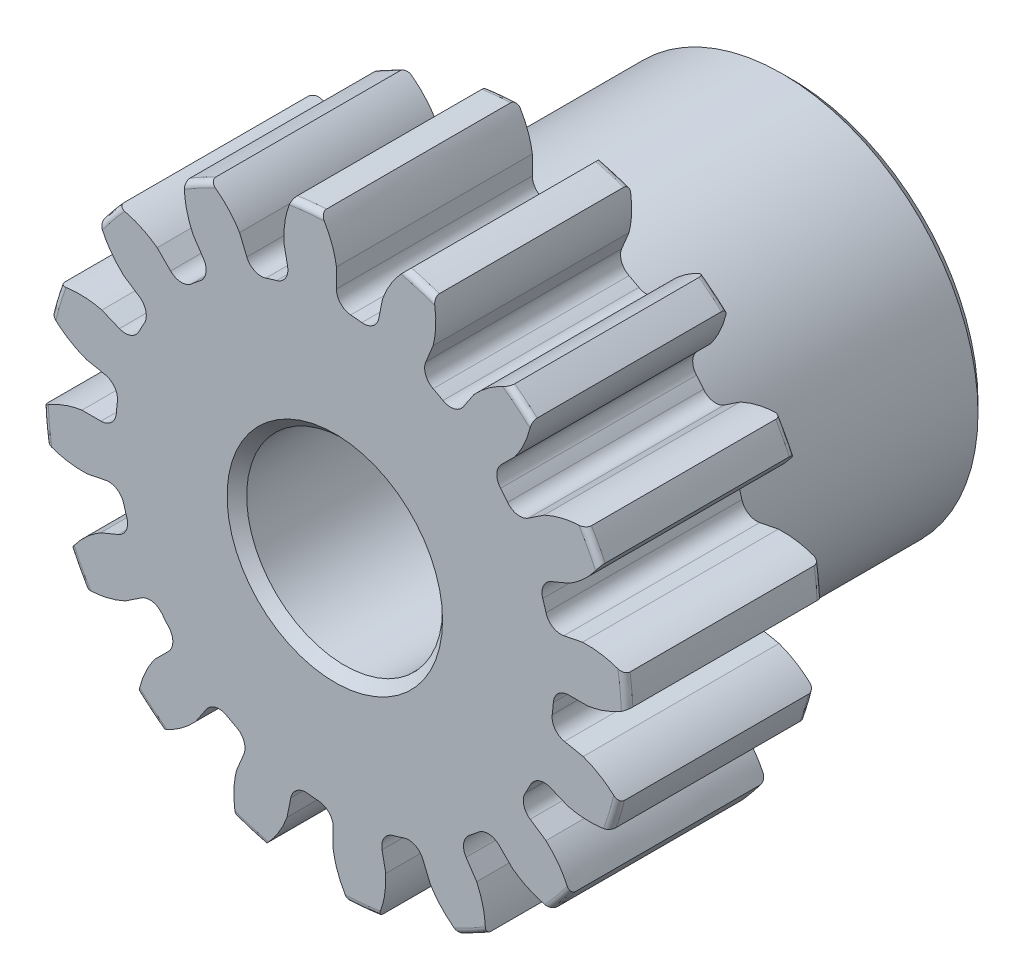
from build123d import *

# Parameters (mm, degrees)
SKETCH1_R                = 7.112
BOSS_EXTRUDE1_DEPTH      = 4.7625
SKETCH2_W                = 6.35
SKETCH2_H                = 4.7625
REVOLVE1_ANGLE           = 360
FILLET2_R                = 0.14224
CUT_EXTRUDE1_DEPTH       = 12.1125
FILLET1_R                = 0.37404675
CIRPATTERN1_COUNT        = 16
FILLET1_OF_CIRPATTERN1_R = 0.37404675
SKETCH5_R                = 2.38125
CUT_EXTRUDE2_DEPTH       = 12.1125
CHAMFER1_SIZE            = 0.238125


with BuildPart() as part:
    # Sketch1 → Boss-Extrude1 (new body)
    with BuildSketch(Plane.XY):
        Circle(SKETCH1_R)
    extrude(amount=-BOSS_EXTRUDE1_DEPTH)

    # Sketch2 → Revolve1 (revolve, symmetric)
    with BuildSketch(Plane(origin=(0, 0, 0), x_dir=(0, 0, -1), z_dir=(1, 0, 0))) as revolve1_sk:
        with Locations((7.9375, 2.38125)):
            Rectangle(SKETCH2_W, SKETCH2_H)
    revolve(axis=Axis((0, 0, -4.7625), (0, 0, -1)), revolution_arc=REVOLVE1_ANGLE / 2)
    revolve(revolve1_sk.sketch, axis=Axis((0, 0, -4.7625), (0, 0, 1)), revolution_arc=REVOLVE1_ANGLE / 2)

    # Fillet2
    fillet2_edges = [part.edges().sort_by_distance(p)[0] for p in [
        (-7.112, 0, 0),
        (-7.112, 0, -4.7625),
        (0, -4.7625, -4.7625),
    ]]
    fillet(fillet2_edges, radius=FILLET2_R)

    # Sketch4 → Cut-Extrude1 (cut, through all)
    with BuildSketch(Plane.XY):
        with BuildLine():
            Line((0.039756598, 6.147608965), (0.039756598, 5.325914116))
            ThreePointArc((0.039756598, 5.325914116), (0.522046632, 5.300415933), (1.000044016, 5.231333838))
            Line((1.000044016, 5.231333838), (1.160349098, 6.037239977))
            add(Edge.make_bspline(
                [(2.084637688, 7.187445149), (1.4115305, 6.736849805), (1.160349098, 6.037239977)],
                knots=[0, 0, 0, 1, 1, 1], degree=2))
            ThreePointArc((2.084637688, 7.187445149), (0.733528106, 7.447618316), (-0.642377547, 7.456033339))
            add(Edge.make_bspline(
                [(-0.642377547, 7.456033339), (-0.070110979, 6.882779097), (0.039756598, 6.147608965)],
                knots=[0, 0, 0, 1, 1, 1], degree=2))
        make_face()
    cut_extrude1 = extrude(amount=-CUT_EXTRUDE1_DEPTH, mode=Mode.SUBTRACT)

    # Fillet1
    fillet1_edges = [part.edges().sort_by_distance(p)[0] for p in [
        (1.000044016, 5.231333838, -2.38125),
        (0.039756598, 5.325914116, -2.38125),
    ]]
    fillet(fillet1_edges, radius=FILLET1_R)

    # CirPattern1: Cut-Extrude1 ×16 about axis
    cirpattern1_axis = Axis((0, 0, -4.7625), (0, 0, 1))
    for i in range(1, CIRPATTERN1_COUNT):
        add(cut_extrude1.rotate(cirpattern1_axis, i * 360 / CIRPATTERN1_COUNT), mode=Mode.SUBTRACT)

    # Fillet1 of CirPattern1
    fillet1_of_cirpattern1_edges = [part.edges().sort_by_distance(p)[0] for p in [
        (-1.078024591, 5.215822537, -2.38125),
        (-2.001408787, 4.935717235, -2.38125),
        (-2.991973726, 4.406249536, -2.38125),
        (-3.737877827, 3.794102147, -2.38125),
        (-4.450421984, 2.925864986, -2.38125),
        (-4.905288852, 2.074869402, -2.38125),
        (-5.231333838, 1.000044016, -2.38125),
        (-5.325914116, 0.039756598, -2.38125),
        (-5.215822537, -1.078024591, -2.38125),
        (-4.935717235, -2.001408787, -2.38125),
        (-4.406249536, -2.991973726, -2.38125),
        (-3.794102147, -3.737877827, -2.38125),
        (-2.925864986, -4.450421984, -2.38125),
        (-2.074869402, -4.905288852, -2.38125),
        (-1.000044016, -5.231333838, -2.38125),
        (-0.039756598, -5.325914116, -2.38125),
        (1.078024591, -5.215822537, -2.38125),
        (2.001408787, -4.935717235, -2.38125),
        (2.991973726, -4.406249536, -2.38125),
        (3.737877827, -3.794102147, -2.38125),
        (4.450421984, -2.925864986, -2.38125),
        (4.905288852, -2.074869402, -2.38125),
        (5.231333838, -1.000044016, -2.38125),
        (5.325914116, -0.039756598, -2.38125),
        (5.215822537, 1.078024591, -2.38125),
        (4.935717235, 2.001408787, -2.38125),
        (4.406249536, 2.991973726, -2.38125),
        (3.794102147, 3.737877827, -2.38125),
        (2.925864986, 4.450421984, -2.38125),
        (2.074869402, 4.905288852, -2.38125),
    ]]
    fillet(fillet1_of_cirpattern1_edges, radius=FILLET1_OF_CIRPATTERN1_R)

    # Sketch5 → Cut-Extrude2 (cut, through all)
    with BuildSketch(Plane.XY):
        Circle(SKETCH5_R)
    extrude(amount=-CUT_EXTRUDE2_DEPTH, mode=Mode.SUBTRACT)

    # Chamfer1
    chamfer1_edges = [part.edges().sort_by_distance(p)[0] for p in [
        (-2.38125, 0, -11.1125),
        (-2.38125, 0, 0),
        (0, -4.7625, -11.1125),
    ]]
    chamfer(chamfer1_edges, length=CHAMFER1_SIZE)


solid = part.part
